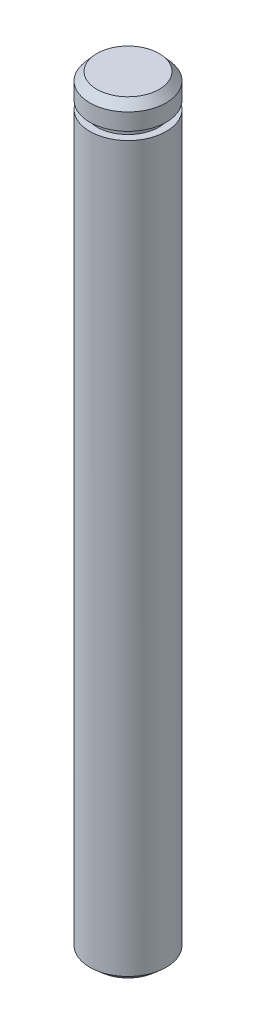
from build123d import *

# Parameters (mm, degrees)
SKETCH1_R             = 4.7625
BOSS_EXTRUDE1_DEPTH   = 47.625
CHAMFER1_SIZE         = 1.016
CHAMFER1_SIZE2        = 0.883195326
CHAMFER1_PART_2_SIZE  = 1.016
CHAMFER1_PART_2_SIZE2 = 0.883195326
SKETCH3_W             = 0.9144
SKETCH3_H             = 0.9906


with BuildPart() as part:
    # Sketch1 → Boss-Extrude1 (new body, symmetric)
    with BuildSketch(Plane(origin=(0, 0, 0), x_dir=(1, 0, 0), z_dir=(0, 1, 0))):
        Circle(SKETCH1_R)
    extrude(amount=BOSS_EXTRUDE1_DEPTH, both=True)

    # Chamfer1
    chamfer1_edges = [part.edges().sort_by_distance(p)[0] for p in [
        (-4.7625, -47.625, 0),
    ]]
    chamfer1_side = [part.faces().sort_by_distance(p)[0] for p in [
        (0, -47.625, 0),
    ]]
    chamfer(chamfer1_edges, length=CHAMFER1_SIZE, length2=CHAMFER1_SIZE2, reference=chamfer1_side[0])

    # Chamfer1 part 2
    chamfer1_part_2_edges = [part.edges().sort_by_distance(p)[0] for p in [
        (-4.7625, 47.625, 0),
    ]]
    chamfer1_part_2_side = [part.faces().sort_by_distance(p)[0] for p in [
        (-4.7625, 0, 0),
    ]]
    chamfer(chamfer1_part_2_edges, length=CHAMFER1_PART_2_SIZE, length2=CHAMFER1_PART_2_SIZE2, reference=chamfer1_part_2_side[0])

    # Sketch3 → Cut-Revolve1 (revolve, cut)
    with BuildSketch(Plane(origin=(0, 0, 0), x_dir=(0, 0, -1), z_dir=(1, 0, 0))):
        with Locations((4.3053, 44.017653665)):
            Rectangle(SKETCH3_W, SKETCH3_H)
    revolve(axis=Axis((0, -47.820758339, 0), (0, 1, 0)), mode=Mode.SUBTRACT)


solid = part.part
